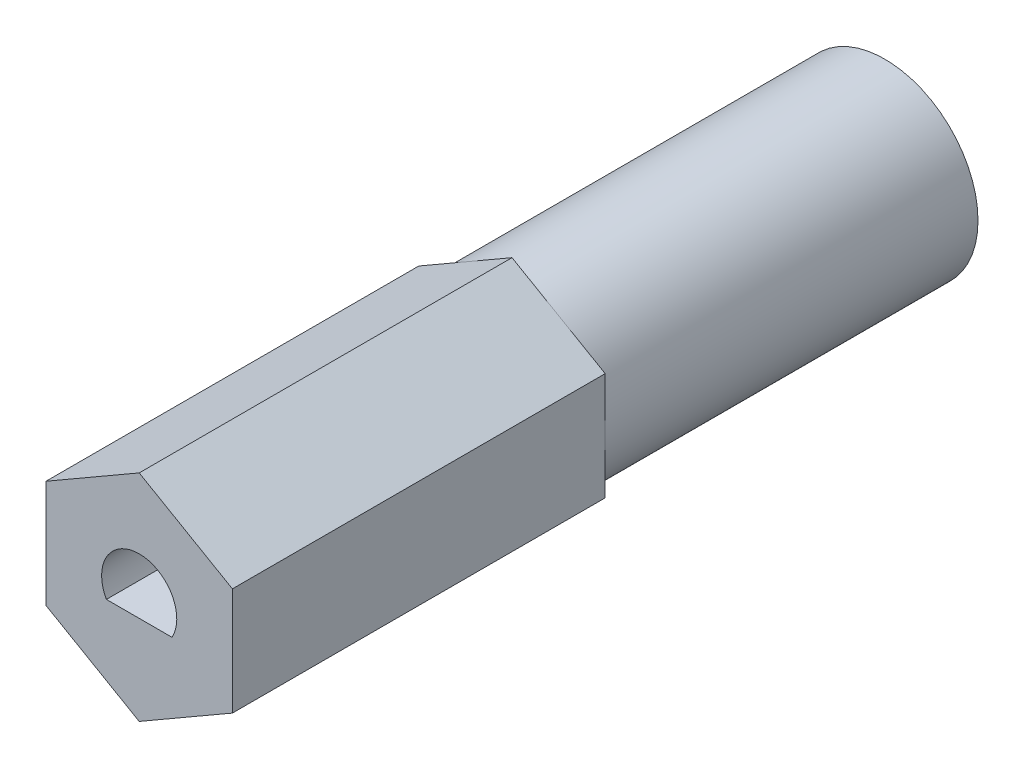
from build123d import *

# Parameters (mm, degrees)
BOSS_EXTRUDE1_DEPTH = 25.4
CUT_EXTRUDE1_DEPTH  = 5.08
SKETCH3_OUTSIDE_W   = 13.788
SKETCH3_OUTSIDE_H   = 14.77
SKETCH3_OUTSIDE_R   = 3.175
CUT_EXTRUDE2_DEPTH  = 13.7


with BuildPart() as part:
    # Sketch1 → Boss-Extrude1 (new body)
    with BuildSketch(Plane.XY):
        Polygon((0, 3.666174209), (-3.175, 1.833087105), (-3.175, -1.833087105), (0, -3.666174209), (3.175, -1.833087105), (3.175, 1.833087105), align=None)
    extrude(amount=-BOSS_EXTRUDE1_DEPTH)

    # Sketch2 → Cut-Extrude1 (cut)
    with BuildSketch(Plane.XY):
        with BuildLine():
            Line((-1.117311326, -0.62484), (1.117311326, -0.62484))
            ThreePointArc((1.117311326, -0.62484), (0, 1.28016), (-1.117311326, -0.62484))
        make_face()
    extrude(amount=-CUT_EXTRUDE1_DEPTH, mode=Mode.SUBTRACT)

    # Sketch3 outside → Cut-Extrude2 (cut, through all)
    with BuildSketch(Plane.XY.offset(-12.7)):
        Rectangle(SKETCH3_OUTSIDE_W, SKETCH3_OUTSIDE_H)
        Circle(SKETCH3_OUTSIDE_R, mode=Mode.SUBTRACT)
    extrude(amount=-CUT_EXTRUDE2_DEPTH, mode=Mode.SUBTRACT)


solid = part.part
